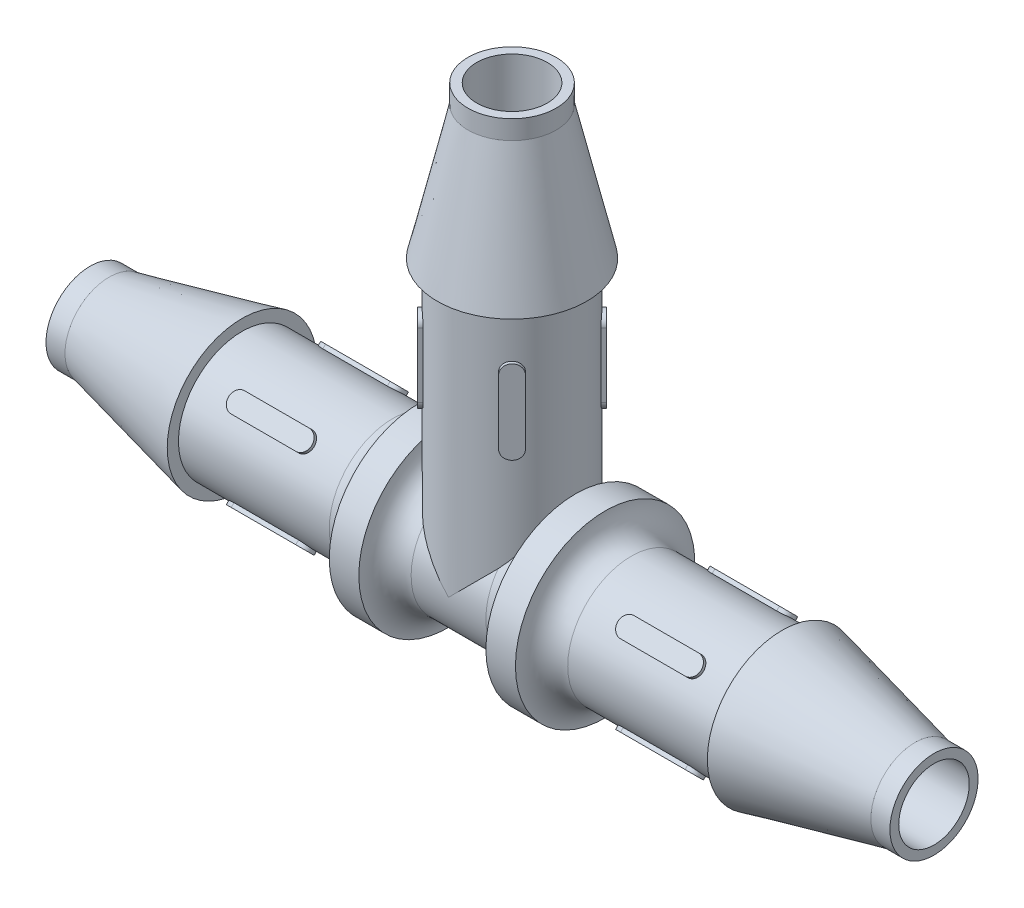
from build123d import *

# Parameters (mm, degrees)
EXTRUDE1_DEPTH     = 2.811018
CIRPATTERN1_COUNT  = 2
CIRPATTERN1_ANGLE  = 90
SKETCH6_R          = 1.4859
CUT_EXTRUDE1_DEPTH = 19.566042831
EXTRUDE2_DEPTH     = 2.811018
CIRPATTERN2_COUNT  = 2
CIRPATTERN2_ANGLE  = 90
SKETCH9_R          = 1.4859
CUT_EXTRUDE2_DEPTH = 40.786171292
SKETCH10_R         = 1.4859
CUT_EXTRUDE3_DEPTH = 26.190359715


with BuildPart() as part:
    # Sketch3 → Revolve1 (revolve)
    with BuildSketch(Plane.XY):
        Polygon((17.78, 1.4859), (17.78, 1.857375), (16.9799, 1.857375), (11.3792, 3.1496), (11.3792, 2.67716), (3.92176, 2.67716), (3.92176, 3.77952), (2.67716, 3.77952), (2.67716, 2.67716), (0, 2.67716), (0, 1.4859), align=None)
    revolve(axis=Axis((0, 0, 0), (1, 0, 0)))

    # Sketch4 → Revolve2 (revolve)
    with BuildSketch(Plane.XY):
        with BuildLine():
            Line((5.02412, 2.67716), (3.92176, 2.67716))
            Line((3.92176, 2.67716), (3.92176, 3.77952))
            ThreePointArc((3.92176, 3.77952), (4.244633769, 3.000033769), (5.02412, 2.67716))
        make_face()
        with BuildLine():
            Line((2.67716, 3.77952), (2.67716, 2.67716))
            Line((2.67716, 2.67716), (1.5748, 2.67716))
            ThreePointArc((1.5748, 2.67716), (2.354286231, 3.000033769), (2.67716, 3.77952))
        make_face()
    revolve(axis=Axis((0, 0, 0), (1, 0, 0)))

    # Sketch5 → Extrude1 (add, symmetric)
    with BuildSketch(Plane(origin=(0, 0, 0), x_dir=(-1, 0, 0), z_dir=(0, 0.7071067811865488, 0.7071067811865462))):
        with BuildLine():
            Line((-6.84149, 0.40005), (-9.56183, 0.40005))
            ThreePointArc((-9.56183, 0.40005), (-9.96188, 0), (-9.56183, -0.40005))
            Line((-9.56183, -0.40005), (-6.84149, -0.40005))
            ThreePointArc((-6.84149, -0.40005), (-6.44144, 0), (-6.84149, 0.40005))
        make_face()
    extrude1 = extrude(amount=EXTRUDE1_DEPTH, both=True)

    # CirPattern1: Extrude1 ×2 about axis
    cirpattern1_axis = Axis((0, 0, 0), (1, 0, 0))
    for i in range(1, CIRPATTERN1_COUNT):
        add(extrude1.rotate(cirpattern1_axis, i * CIRPATTERN1_ANGLE / (CIRPATTERN1_COUNT - 1)))

    # Sketch6 → Cut-Extrude1 (cut, through all)
    with BuildSketch(Plane(origin=(17.78, 0, 0), x_dir=(0, 0, -1), z_dir=(1, 0, 0))):
        Circle(SKETCH6_R)
    extrude(amount=-CUT_EXTRUDE1_DEPTH, mode=Mode.SUBTRACT)

    # Sketch7 → Revolve3 (revolve)
    with BuildSketch(Plane.XY):
        Polygon((1.4859, 17.43964), (1.857375, 17.43964), (1.857375, 16.63954), (3.1496, 11.03884), (2.67716, 11.03884), (2.67716, 0), (1.4859, 0), align=None)
    revolve(axis=Axis((0, 0, 0), (0, 1, 0)))

    # Mirror1: part across plane


with BuildPart() as part_1:
    add(part.part)
    add(part.part.mirror(Plane(origin=(0, 0, 0), x_dir=(0, 0, 1), z_dir=(1, 0, 0))))

    # Sketch8 → Extrude2 (add, symmetric)
    with BuildSketch(Plane(origin=(0, 0, 0), x_dir=(0.7071067811865462, 0, 0.7071067811865488), z_dir=(-0.7071067811865488, 0, 0.7071067811865462))):
        with BuildLine():
            Line((-0.40005, 8.76935), (-0.40005, 6.04901))
            ThreePointArc((-0.40005, 6.04901), (0, 5.64896), (0.40005, 6.04901))
            Line((0.40005, 6.04901), (0.40005, 8.76935))
            ThreePointArc((0.40005, 8.76935), (0, 9.1694), (-0.40005, 8.76935))
        make_face()
    extrude2 = extrude(amount=EXTRUDE2_DEPTH, both=True)

    # CirPattern2: Extrude2 ×2 about axis
    cirpattern2_axis = Axis((0, 0, 0), (0, 1, 0))
    for i in range(1, CIRPATTERN2_COUNT):
        add(extrude2.rotate(cirpattern2_axis, i * CIRPATTERN2_ANGLE / (CIRPATTERN2_COUNT - 1)))

    # Sketch9 → Cut-Extrude2 (cut, through all)
    with BuildSketch(Plane(origin=(17.78, 0, 0), x_dir=(0, 0, -1), z_dir=(1, 0, 0))):
        Circle(SKETCH9_R)
    extrude(amount=-CUT_EXTRUDE2_DEPTH, mode=Mode.SUBTRACT)

    # Sketch10 → Cut-Extrude3 (cut, through all)
    with BuildSketch(Plane(origin=(0, 0, 0), x_dir=(1, 0, 0), z_dir=(0, 1, 0))):
        Circle(SKETCH10_R)
    extrude(amount=CUT_EXTRUDE3_DEPTH, mode=Mode.SUBTRACT)


solid = part_1.part
